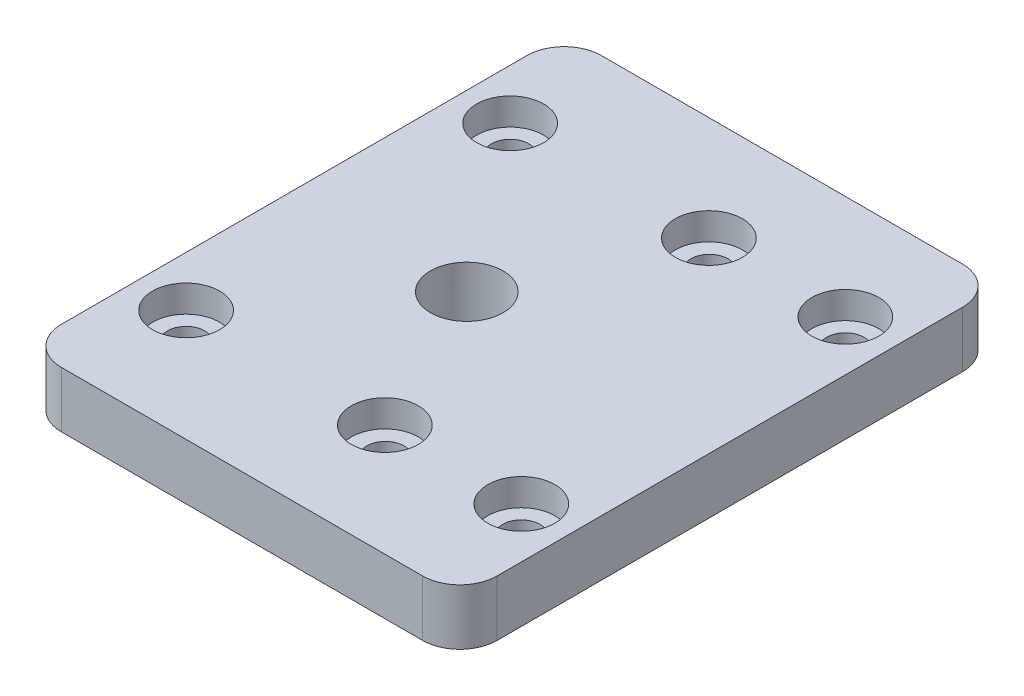
from build123d import *

# Parameters (mm, degrees)
BOSS_EXTRUDE1_DEPTH   = 3
BOSS_EXTRUDE1_2_DEPTH = 3
SKETCH1_W             = 23.4
SKETCH1_H             = 29
SKETCH1_R             = 1
BOSS_EXTRUDE1_3_DEPTH = 3
FILLET1_R             = 2
SKETCH5_R             = 1.44
CUT_EXTRUDE3_DEPTH    = 10
CUT_EXTRUDE4_DEPTH    = 10
SKETCH8_R             = 1
CUT_EXTRUDE5_DEPTH    = 10
SKETCH9_R             = 3.026992654
BOSS_EXTRUDE3_DEPTH   = 3
SKETCH10_R            = 1.95
CUT_EXTRUDE6_DEPTH    = 10
SKETCH11_R            = 1.8
CUT_EXTRUDE7_DEPTH    = 1.45


with BuildPart() as part:
    # Sketch1 → Boss-Extrude1 (new body)
    with BuildSketch(Plane(origin=(0, 0, 0), x_dir=(1, 0, 0), z_dir=(0, 1, 0))):
        with BuildLine():
            add(Edge.make_bspline(
                [(19.180993887, -14.242526212), (19.80083761, -12.341053413), (17.899318471, -11.721194585), (17.279474749, -13.622667384), (16.659631026, -15.524140184), (18.561150164, -16.143999012), (19.180993887, -14.242526212)],
                knots=[0, 0, 0, 0, 0.5, 0.5, 0.5, 1, 1, 1, 1], degree=3, weights=[1, 0.333333333, 0.333333333, 1, 0.333333333, 0.333333333, 1]))
        make_face()
    extrude(amount=BOSS_EXTRUDE1_DEPTH)


with BuildPart() as body_2:
    # Sketch1 → Boss-Extrude1 2 (new body)
    with BuildSketch(Plane(origin=(0, 0, 0), x_dir=(1, 0, 0), z_dir=(0, 1, 0))):
        with BuildLine():
            add(Edge.make_bspline(
                [(22.488505608, -4.096188772), (23.108349331, -2.194715972), (21.206830193, -1.574857144), (20.58698647, -3.476329943), (19.967142747, -5.377802743), (21.868661885, -5.997661571), (22.488505608, -4.096188772)],
                knots=[0, 0, 0, 0, 0.5, 0.5, 0.5, 1, 1, 1, 1], degree=3, weights=[1, 0.333333333, 0.333333333, 1, 0.333333333, 0.333333333, 1]))
        make_face()
    extrude(amount=BOSS_EXTRUDE1_2_DEPTH)


with BuildPart() as body_3:
    # Sketch1 → Boss-Extrude1 3 (new body)
    with BuildSketch(Plane(origin=(0, 0, 0), x_dir=(1, 0, 0), z_dir=(0, 1, 0))):
        Rectangle(SKETCH1_W, SKETCH1_H)
        with Locations(Location((9, 8.9, 0), (0, 0, 270))):
            Circle(SKETCH1_R, mode=Mode.SUBTRACT)
        with Locations(Location((9, -8.5, 0), (0, 0, 90))):
            Circle(SKETCH1_R, mode=Mode.SUBTRACT)
        with Locations(Location((-9, -8.5, 0), (0, 0, 90))):
            Circle(SKETCH1_R, mode=Mode.SUBTRACT)
        with Locations(Location((1.7, -8.5, 0), (0, 0, 90))):
            Circle(SKETCH1_R, mode=Mode.SUBTRACT)
    extrude(amount=BOSS_EXTRUDE1_3_DEPTH)

    # Fillet1
    fillet1_edges = [body_3.edges().sort_by_distance(p)[0] for p in [
        (11.7, 1.5, 14.5),
        (-11.7, 1.5, 14.5),
        (-11.7, 1.5, -14.5),
        (11.7, 1.5, -14.5),
    ]]
    fillet(fillet1_edges, radius=FILLET1_R)

    # Sketch5 → Cut-Extrude3 (cut)
    with BuildSketch(Plane.XZ):
        with Locations(Location((-2.145634177, 3.61037734, 0), (0, 0, 270))):
            Circle(SKETCH5_R)
    extrude(amount=-CUT_EXTRUDE3_DEPTH, mode=Mode.SUBTRACT)

    # Sketch8 → Cut-Extrude5 (cut)
    with BuildSketch(Plane(origin=(0, 3, 0), x_dir=(1, 0, 0), z_dir=(0, 1, 0))):
        with Locations(Location((1.7, 8.9, 0), (0, 0, 270))):
            Circle(SKETCH8_R)
        with Locations(Location((-9, 8.9, 0), (0, 0, 270))):
            Circle(SKETCH8_R)
    extrude(amount=-CUT_EXTRUDE5_DEPTH, mode=Mode.SUBTRACT)

    # Sketch9 → Boss-Extrude3 (add)
    with BuildSketch(Plane(origin=(0, 3, 0), x_dir=(1, 0, 0), z_dir=(0, 1, 0))):
        with Locations((-2.145634177, -3.61037734)):
            Circle(SKETCH9_R)
    extrude(amount=-BOSS_EXTRUDE3_DEPTH)

    # Sketch10 → Cut-Extrude6 (cut)
    with BuildSketch(Plane(origin=(0, 3, 0), x_dir=(1, 0, 0), z_dir=(0, 1, 0))):
        with Locations(Location((-2.328177417, -0.1, 0), (0, 0, 270))):
            Circle(SKETCH10_R)
    extrude(amount=-CUT_EXTRUDE6_DEPTH, mode=Mode.SUBTRACT)

    # Sketch11 → Cut-Extrude7 (cut)
    with BuildSketch(Plane(origin=(0, 3, 0), x_dir=(1, 0, 0), z_dir=(0, 1, 0))):
        with Locations(Location((-9, -8.5, 0), (0, 0, 270))):
            Circle(SKETCH11_R)
        with Locations(Location((1.671822583, -8.5, 0), (0, 0, 270))):
            Circle(SKETCH11_R)
        with Locations(Location((9, -8.5, 0), (0, 0, 270))):
            Circle(SKETCH11_R)
        with Locations(Location((9, 8.9, 0), (0, 0, 270))):
            Circle(SKETCH11_R)
        with Locations(Location((1.671822583, 8.9, 0), (0, 0, 270))):
            Circle(SKETCH11_R)
        with Locations(Location((-9, 8.9, 0), (0, 0, 270))):
            Circle(SKETCH11_R)
    extrude(amount=-CUT_EXTRUDE7_DEPTH, mode=Mode.SUBTRACT)


with BuildPart() as cut_extrude4_tool:
    # Sketch7 → Cut-Extrude4 (new body)
    with BuildSketch(Plane(origin=(0, 3, 0), x_dir=(1, 0, 0), z_dir=(0, 1, 0))):
        with BuildLine():
            add(Edge.make_bspline(
                [(19.180993887, -14.242526212), (19.80083761, -12.341053413), (17.899318471, -11.721194585), (17.279474749, -13.622667384), (16.659631026, -15.524140184), (18.561150164, -16.143999012), (19.180993887, -14.242526212)],
                knots=[0, 0, 0, 0, 0.5, 0.5, 0.5, 1, 1, 1, 1], degree=3, weights=[1, 0.333333333, 0.333333333, 1, 0.333333333, 0.333333333, 1]))
        make_face()
        with BuildLine():
            add(Edge.make_bspline(
                [(22.488505608, -4.096188772), (23.108349331, -2.194715972), (21.206830193, -1.574857144), (20.58698647, -3.476329943), (19.967142747, -5.377802743), (21.868661885, -5.997661571), (22.488505608, -4.096188772)],
                knots=[0, 0, 0, 0, 0.5, 0.5, 0.5, 1, 1, 1, 1], degree=3, weights=[1, 0.333333333, 0.333333333, 1, 0.333333333, 0.333333333, 1]))
        make_face()
    extrude(amount=-CUT_EXTRUDE4_DEPTH)


with BuildPart() as part_1:
    add(part.part)

    # Cut-Extrude4: cut by cut_extrude4_tool
    add(cut_extrude4_tool.part, mode=Mode.SUBTRACT)


with BuildPart() as body_2_1:
    add(body_2.part)

    # Cut-Extrude4: cut by cut_extrude4_tool
    add(cut_extrude4_tool.part, mode=Mode.SUBTRACT)


solid = body_3.part
